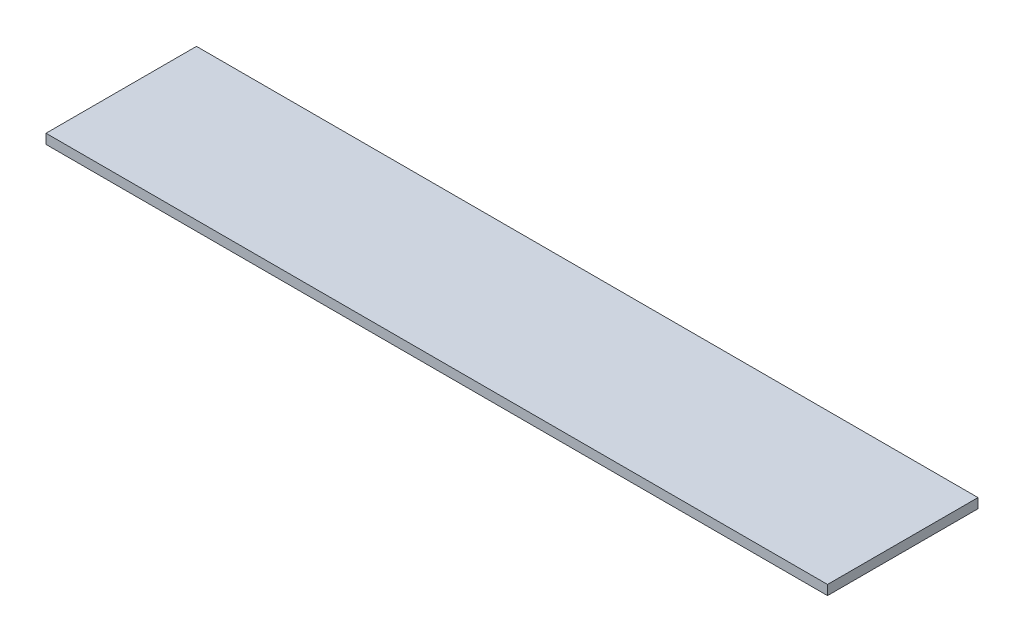
from build123d import *

# Parameters (mm, degrees)
SKETCH1_W           = 511.175
SKETCH1_H           = 98.425
BOSS_EXTRUDE1_DEPTH = 6.35


with BuildPart() as part:
    # Sketch1 → Boss-Extrude1 (new body)
    with BuildSketch(Plane(origin=(0, 0, 0), x_dir=(1, 0, 0), z_dir=(0, 1, 0))):
        with Locations((255.5875, 49.2125)):
            Rectangle(SKETCH1_W, SKETCH1_H)
    extrude(amount=BOSS_EXTRUDE1_DEPTH)


solid = part.part
